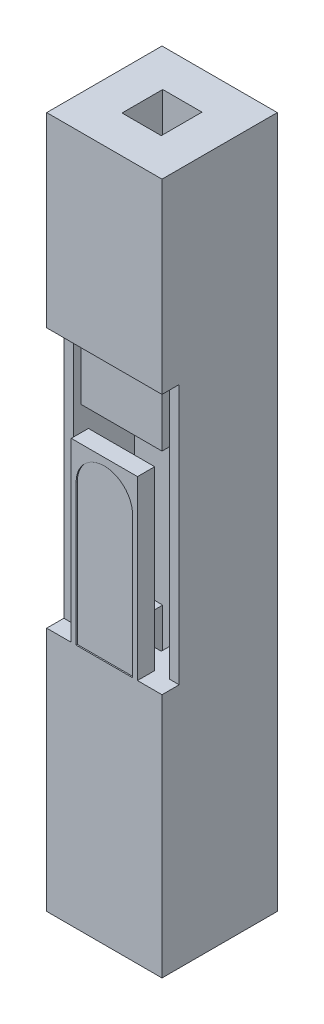
from build123d import *

# Parameters (mm, degrees)
SKETCH2_W           = 2.35
SKETCH2_H           = 2.35
BOSS_EXTRUDE1_DEPTH = 7.05
PINHOLE_REACH       = 16.1
SKETCH3_W           = 0.8
SKETCH3_H           = 0.83
CUT_EXTRUDE2_DEPTH  = 0.35
SKETCH5_W           = 1.95
SKETCH5_H           = 5.3
CUT_EXTRUDE3_DEPTH  = 1.24
CUT_EXTRUDE5_DEPTH  = 0.025
SKETCH7_W           = 1.95
SKETCH7_H           = 1.95
CUT_EXTRUDE6_DEPTH  = 4
SKETCH9_W           = 0.15
SKETCH9_H           = 1
HOLDER_1_DEPTH      = 1.09
SKETCH10_W          = 1.65
SKETCH10_H          = 1
HOLDER_2_DEPTH      = 0.15


with BuildPart() as part:
    # Sketch2 → Boss-Extrude1 (new body, symmetric)
    with BuildSketch(Plane(origin=(0, 0, 0), x_dir=(1, 0, 0), z_dir=(0, 1, 0))):
        Rectangle(SKETCH2_W, SKETCH2_H)
    extrude(amount=BOSS_EXTRUDE1_DEPTH, both=True)

    # Sketch3 → Pinhole (cut, up to next)
    with BuildSketch(Plane(origin=(0, 7.05, 0), x_dir=(1, 0, 0), z_dir=(0, 1, 0)), mode=Mode.PRIVATE) as pinhole_sk1:
        Rectangle(SKETCH3_W, SKETCH3_H)
    pinhole_tool1 = extrude(pinhole_sk1.sketch, amount=-PINHOLE_REACH, mode=Mode.PRIVATE) & part.part
    add(pinhole_tool1.solids().sort_by_distance((0, 7.05, 0))[0], mode=Mode.SUBTRACT)

    # Sketch4 → Cut-Extrude2 (cut)
    with BuildSketch(Plane.XY.offset(1.175)):
        Polygon((-1.175, 3.25), (1.175, 3.25), (1.175, -2.05), (0.675, -2.05), (0.675, 1.55), (-0.675, 1.55), (-0.675, -2.05), (-1.175, -2.05), align=None)
    extrude(amount=-CUT_EXTRUDE2_DEPTH, mode=Mode.SUBTRACT)

    # Sketch5 → Cut-Extrude3 (cut)
    with BuildSketch(Plane.XY.offset(0.825)):
        with Locations((0, 0.6)):
            Rectangle(SKETCH5_W, SKETCH5_H)
    extrude(amount=-CUT_EXTRUDE3_DEPTH, mode=Mode.SUBTRACT)

    # Sketch6 → Cut-Extrude5 (cut)
    with BuildSketch(Plane.XY.offset(1.175)):
        with BuildLine():
            Line((-0.575, 0.825), (-0.575, -2.05))
            Line((-0.575, -2.05), (0.575, -2.05))
            Line((0.575, -2.05), (0.575, 0.825))
            ThreePointArc((0.575, 0.825), (0, 1.4), (-0.575, 0.825))
        make_face()
    extrude(amount=-CUT_EXTRUDE5_DEPTH, mode=Mode.SUBTRACT)

    # Sketch7 → Cut-Extrude6 (cut)
    with BuildSketch(Plane.XZ.offset(7.05)):
        Rectangle(SKETCH7_W, SKETCH7_H)
    extrude(amount=-CUT_EXTRUDE6_DEPTH, mode=Mode.SUBTRACT)

    # Sketch9 → Holder-1 (add)
    with BuildSketch(Plane.XY.offset(-0.415)):
        with Locations((-0.75, 2.4)):
            Rectangle(SKETCH9_W, SKETCH9_H)
        with Locations((0.75, 2.4)):
            Rectangle(SKETCH9_W, SKETCH9_H)
    extrude(amount=HOLDER_1_DEPTH)

    # Sketch10 → Holder-2 (add)
    with BuildSketch(Plane.XY.offset(0.675)):
        with Locations((0, 2.4)):
            Rectangle(SKETCH10_W, SKETCH10_H)
    extrude(amount=HOLDER_2_DEPTH)


solid = part.part
